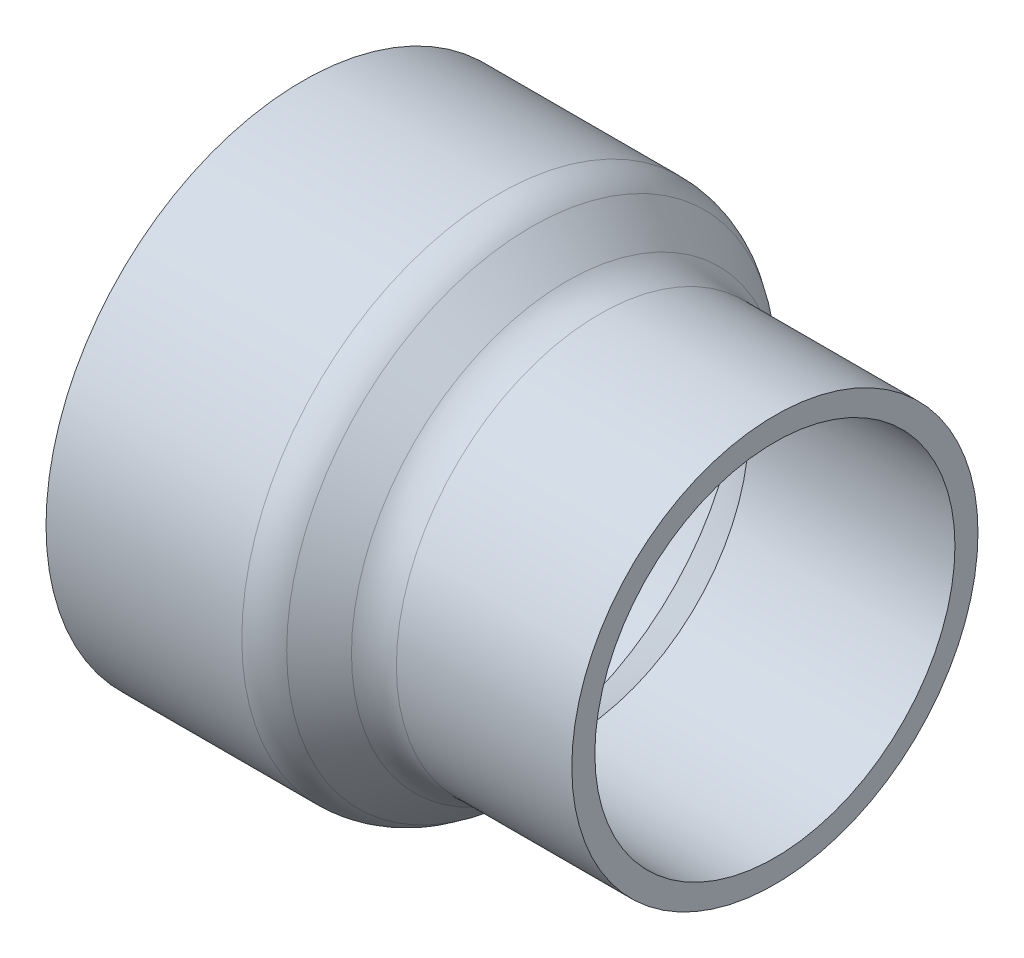
from build123d import *

# Parameters (mm, degrees)
FILLET1_R = 12.7


with BuildPart() as part:
    # Sketch1 → Revolve1 (revolve)
    with BuildSketch(Plane.XY):
        Polygon((-7.2517, -57.0357), (7.80462683, -44.40194171), (7.7597, -44.3484), (58.5597, -44.6532), (58.5597, -50.3682), (10.434859531, -50.3682), (-5.381498273, -63.6397), (-58.5597, -63.6397), (-58.5597, -57.3786), align=None)
    revolve(axis=Axis((-58.5597, 0, 0), (1, 0, 0)))

    # Fillet1
    fillet1_edges = [part.edges().sort_by_distance(p)[0] for p in [
        (-5.381498273, 63.6397, 0),
        (10.434859531, 50.3682, 0),
    ]]
    fillet(fillet1_edges, radius=FILLET1_R)


solid = part.part
